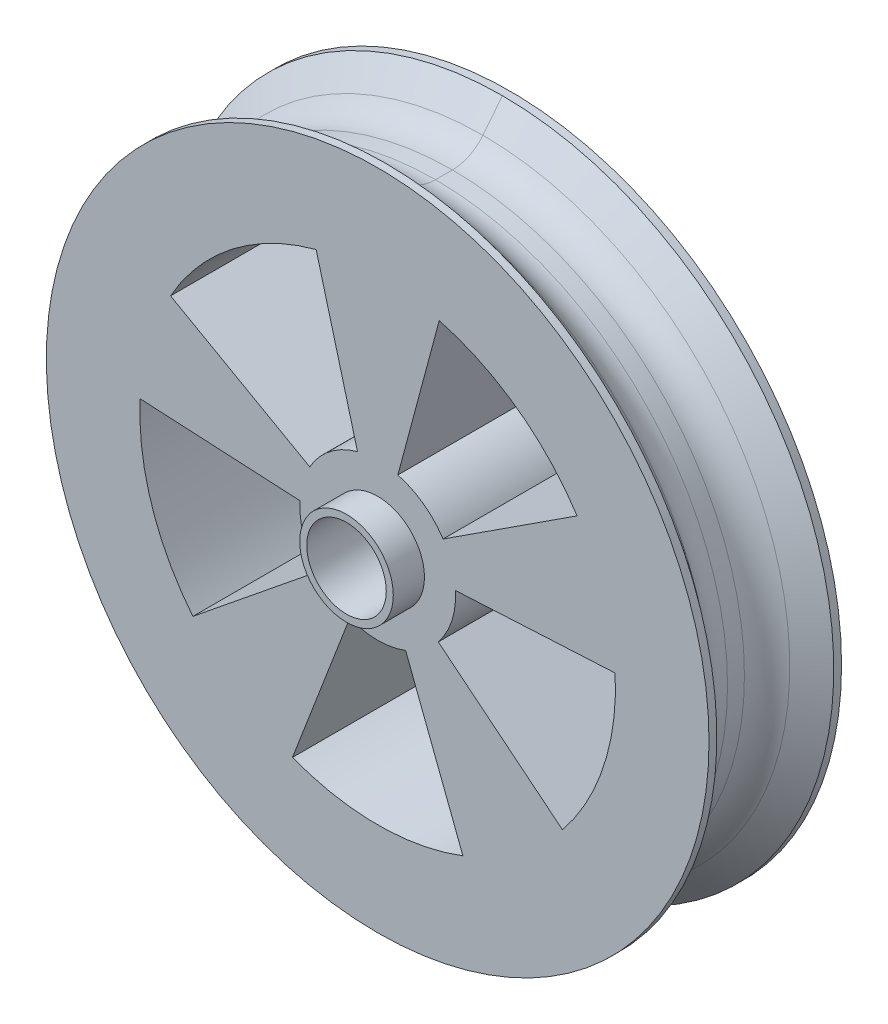
from build123d import *

# Parameters (mm, degrees)
SKETCH1_R           = 42.5
BOSS_EXTRUDE1_DEPTH = 17
CUT_EXTRUDE3_DEPTH  = 17
SKETCH4_R           = 5.1
CUT_EXTRUDE4_DEPTH  = 17
SKETCH5_R           = 6
SKETCH5_R_2         = 5.1
BOSS_EXTRUDE2_DEPTH = 4
SKETCH6_R           = 6
SKETCH6_R_2         = 5.1
BOSS_EXTRUDE3_DEPTH = 4
FILLET1_R           = 5
FILLET2_R           = 5


with BuildPart() as part:
    # Sketch1 → Boss-Extrude1 (new body)
    with BuildSketch(Plane.XY):
        Circle(SKETCH1_R)
    extrude(amount=BOSS_EXTRUDE1_DEPTH)

    # Sketch3 → Cut-Extrude3 (cut)
    with BuildSketch(Plane.XY.offset(17)):
        with BuildLine():
            ThreePointArc((-8.711670849, 4.9098667), (-6.128694511, 7.901841785), (-2.588190451, 9.659258263))
            Line((-2.588190451, 9.659258263), (-7.893980876, 29.460737702))
            ThreePointArc((-7.893980876, 29.460737702), (-18.692518258, 24.100617444), (-26.570596091, 14.975093435))
            Line((-26.570596091, 14.975093435), (-8.711670849, 4.9098667))
        make_face()
        with BuildLine():
            Line((7.893980876, 29.460737702), (2.588190451, 9.659258263))
            ThreePointArc((2.588190451, 9.659258263), (5.877852523, 8.090169944), (8.386705679, 5.44639035))
            Line((8.386705679, 5.44639035), (25.579452322, 16.611490568))
            ThreePointArc((25.579452322, 16.611490568), (17.927450195, 24.675018328), (7.893980876, 29.460737702))
        make_face()
        with BuildLine():
            Line((30.45820081, 1.596246665), (9.986295348, 0.523359562))
            ThreePointArc((9.986295348, 0.523359562), (9.99657325, 0.261769483), (10, 0))
            ThreePointArc((10, 0), (9.426414911, -3.338068592), (7.771459615, -6.29320391))
            Line((7.771459615, -6.29320391), (23.702951824, -19.194271927))
            ThreePointArc((23.702951824, -19.194271927), (28.750565478, -10.181109207), (30.5, 0))
            ThreePointArc((30.5, 0), (30.489548412, 0.798396923), (30.45820081, 1.596246665))
        make_face()
        with BuildLine():
            Line((10.930222461, -28.474203008), (3.583679495, -9.335804265))
            ThreePointArc((3.583679495, -9.335804265), (0, -10), (-3.583679495, -9.335804265))
            Line((-3.583679495, -9.335804265), (-10.930222461, -28.474203008))
            ThreePointArc((-10.930222461, -28.474203008), (0, -30.5), (10.930222461, -28.474203008))
        make_face()
        with BuildLine():
            Line((-23.702951824, -19.194271927), (-7.771459615, -6.29320391))
            ThreePointArc((-7.771459615, -6.29320391), (-9.510565163, -3.090169944), (-9.986295348, 0.523359562))
            Line((-9.986295348, 0.523359562), (-30.45820081, 1.596246665))
            ThreePointArc((-30.45820081, 1.596246665), (-29.007223747, -9.425018328), (-23.702951824, -19.194271927))
        make_face()
    extrude(amount=-CUT_EXTRUDE3_DEPTH, mode=Mode.SUBTRACT)

    # Sketch4 → Cut-Extrude4 (cut)
    with BuildSketch(Plane.XY.offset(17)):
        Circle(SKETCH4_R)
    extrude(amount=-CUT_EXTRUDE4_DEPTH, mode=Mode.SUBTRACT)

    # Sketch5 → Boss-Extrude2 (add)
    with BuildSketch(Plane.XY.offset(17)):
        Circle(SKETCH5_R)
        Circle(SKETCH5_R_2, mode=Mode.SUBTRACT)
    extrude(amount=BOSS_EXTRUDE2_DEPTH)

    # Sketch6 → Boss-Extrude3 (add)
    with BuildSketch(Plane(origin=(0, 0, 0), x_dir=(-1, 0, 0), z_dir=(0, 0, -1))):
        Circle(SKETCH6_R)
        Circle(SKETCH6_R_2, mode=Mode.SUBTRACT)
    extrude(amount=BOSS_EXTRUDE3_DEPTH)

    # Sketch10 → Cut-Revolve1 (revolve, cut)
    with BuildSketch(Plane(origin=(0, 0, 0), x_dir=(0, 0, -1), z_dir=(1, 0, 0))):
        Polygon((-16, 42.5), (-8.5, 42.5), (-8.5, 37.459040498), (-12, 37.459040498), align=None)
        Polygon((-8.5, 42.5), (-1, 42.5), (-5, 37.459040498), (-8.5, 37.459040498), align=None)
    revolve(axis=Axis((0, 0, 0), (0, 0, -1)), mode=Mode.SUBTRACT)

    # Fillet1
    fillet1_edges = [part.edges().sort_by_distance(p)[0] for p in [
        (0, -37.459040498, 5),
    ]]
    fillet(fillet1_edges, radius=FILLET1_R)

    # Fillet2
    fillet2_edges = [part.edges().sort_by_distance(p)[0] for p in [
        (0, -37.459040498, 12),
    ]]
    fillet(fillet2_edges, radius=FILLET2_R)


solid = part.part
